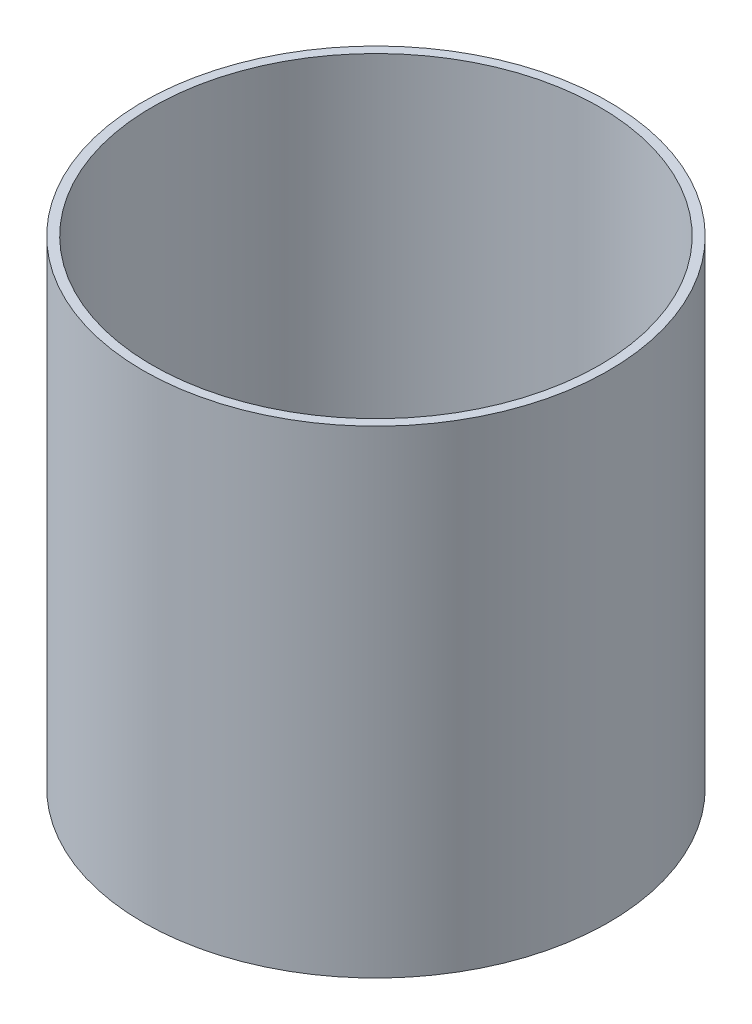
from build123d import *

# Parameters (mm, degrees)
SKETCH1_R           = 38
SKETCH1_R_2         = 36.5
EXTRUDE_THIN1_DEPTH = 78


with BuildPart() as part:
    # Sketch1 → Extrude-Thin1 (new body)
    with BuildSketch(Plane(origin=(0, 0, 0), x_dir=(1, 0, 0), z_dir=(0, 1, 0))):
        Circle(SKETCH1_R)
        Circle(SKETCH1_R_2, mode=Mode.SUBTRACT)
    extrude(amount=EXTRUDE_THIN1_DEPTH)


solid = part.part
